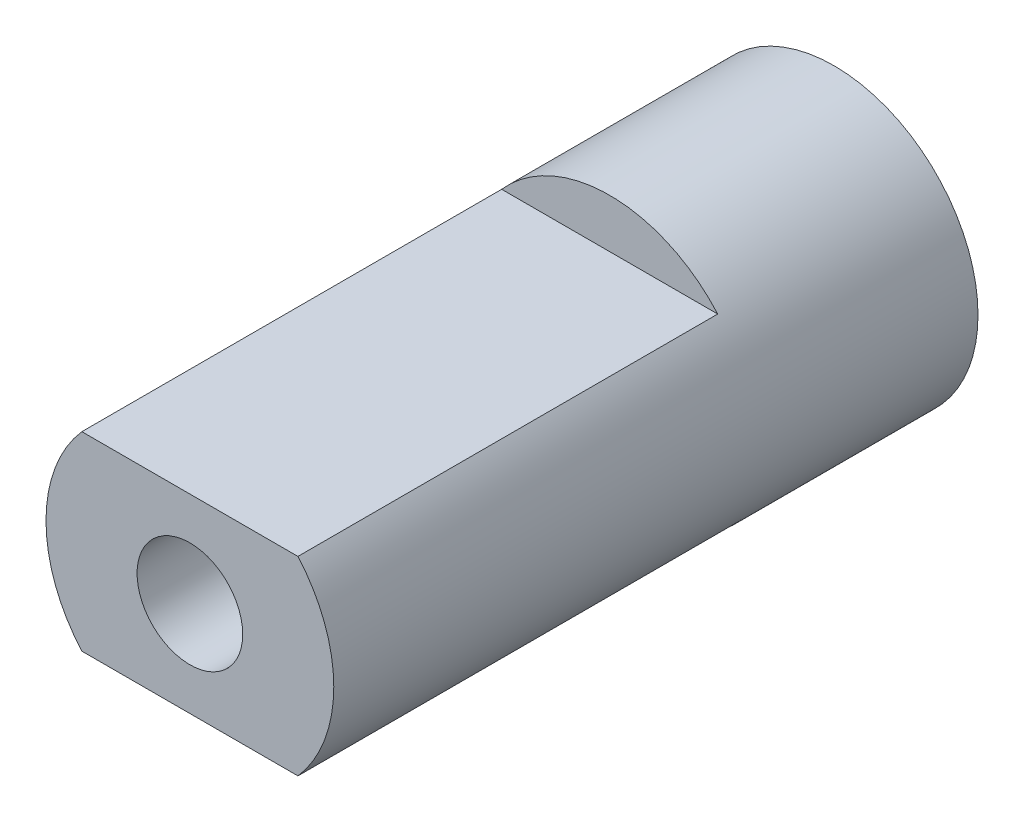
from build123d import *
from build123d.topology import SkipClean

# Parameters (mm, degrees)
SKETCH1_R           = 1
BOSS_EXTRUDE1_DEPTH = 3
BOSS_EXTRUDE2_START = 0.5
SKETCH2_R           = 1.75
SKETCH2_R_2         = 1
BOSS_EXTRUDE2_DEPTH = 0.5
SKETCH3_R           = 2.725
SKETCH3_R_2         = 1
BOSS_EXTRUDE3_DEPTH = 10.3
CUT_EXTRUDE1_START  = -7.95
CUT_EXTRUDE1_DEPTH  = 7.95
CUT_EXTRUDE3_DEPTH  = 3.5
CUT_EXTRUDE4_START  = -8.4
CUT_EXTRUDE4_DEPTH  = 8.4
BOSS_EXTRUDE4_START = -12.2
SKETCH9_R           = 1
BOSS_EXTRUDE4_DEPTH = 12.2
BOSS_EXTRUDE5_START = 1.9
BOSS_EXTRUDE5_DEPTH = 1.9


with BuildPart() as part:
    # Sketch1 → Boss-Extrude1 (new body)
    with BuildSketch(Plane.XY):
        with BuildLine():
            Line((1.642723432, 9.052152215), (1.930369102, 8.457499638))
            Line((1.930369102, 8.457499638), (1.813545612, 7.945662484))
            ThreePointArc((1.813545612, 7.945662484), (1.99137431, 7.902969591), (2.168200291, 7.856297315))
            ThreePointArc((2.168200291, 7.856297315), (2.343934519, 7.805669156), (2.518488504, 7.751110608))
            Line((2.518488504, 7.751110608), (2.680722426, 8.250415279))
            Line((2.680722426, 8.250415279), (3.232648382, 8.61336081))
            Line((3.232648382, 8.61336081), (3.409492149, 7.976903427))
            Line((3.409492149, 7.976903427), (3.203154008, 7.494151346))
            ThreePointArc((3.203154008, 7.494151346), (3.370501815, 7.420392005), (3.536152474, 7.342896273))
            ThreePointArc((3.536152474, 7.342896273), (3.700022573, 7.261703172), (3.862029599, 7.176853585))
            Line((3.862029599, 7.176853585), (4.110810647, 7.639166239))
            Line((4.110810647, 7.639166239), (4.718673352, 7.897728901))
            Line((4.718673352, 7.897728901), (4.779031314, 7.239922976))
            Line((4.779031314, 7.239922976), (4.489810399, 6.801772018))
            ThreePointArc((4.489810399, 6.801772018), (4.641298619, 6.699316915), (4.790449806, 6.593488504))
            ThreePointArc((4.790449806, 6.593488504), (4.937188857, 6.484340073), (5.081441885, 6.371926582))
            Line((5.081441885, 6.371926582), (5.408774031, 6.78238811))
            Line((5.408774031, 6.78238811), (6.053036279, 6.928257487))
            Line((6.053036279, 6.928257487), (5.99496848, 6.270245444))
            Line((5.99496848, 6.270245444), (5.632160589, 5.89077814))
            ThreePointArc((5.632160589, 5.89077814), (5.762920267, 5.762920267), (5.89077814, 5.632160589))
            ThreePointArc((5.89077814, 5.632160589), (6.01566983, 5.498564949), (6.137532448, 5.362200616))
            Line((6.137532448, 5.362200616), (6.532894968, 5.707618447))
            Line((6.532894968, 5.707618447), (7.192849639, 5.736106177))
            Line((7.192849639, 5.736106177), (7.018222426, 5.099037064))
            Line((7.018222426, 5.099037064), (6.593488504, 4.790449806))
            ThreePointArc((6.593488504, 4.790449806), (6.699316915, 4.641298619), (6.801772018, 4.489810399))
            ThreePointArc((6.801772018, 4.489810399), (6.900802224, 4.336061424), (6.996357668, 4.180129111))
            Line((6.996357668, 4.180129111), (7.447043285, 4.449401231))
            Line((7.447043285, 4.449401231), (8.101478893, 4.359591695))
            Line((8.101478893, 4.359591695), (7.815904929, 3.763941437))
            Line((7.815904929, 3.763941437), (7.342896273, 3.536152474))
            ThreePointArc((7.342896273, 3.536152474), (7.420392005, 3.370501816), (7.494151346, 3.203154008))
            ThreePointArc((7.494151346, 3.203154008), (7.564137156, 3.034193316), (7.630314196, 2.863704816))
            Line((7.630314196, 2.863704816), (8.121837503, 3.048176599))
            Line((8.121837503, 3.048176599), (8.74971995, 2.842956348))
            Line((8.74971995, 2.842956348), (8.362377816, 2.307869635))
            Line((8.362377816, 2.307869635), (7.856297315, 2.168200292))
            ThreePointArc((7.856297315, 2.168200292), (7.902969591, 1.99137431), (7.945662484, 1.813545612))
            ThreePointArc((7.945662484, 1.813545612), (7.984354497, 1.634803739), (8.019026147, 1.455238692))
            Line((8.019026147, 1.455238692), (8.535589181, 1.548981062))
            Line((8.535589181, 1.548981062), (9.116737808, 1.234946046))
            Line((9.116737808, 1.234946046), (8.640077, 0.777621005))
            Line((8.640077, 0.777621005), (8.117190496, 0.730560368))
            ThreePointArc((8.117190496, 0.730560368), (8.131539232, 0.548242396), (8.141793492, 0.365648367))
            ThreePointArc((8.141793492, 0.365648367), (8.147948115, 0.182870224), (8.15, 0))
            Line((8.15, 0), (8.675, 0))
            Line((8.675, 0), (9.190736212, -0.412756439))
            Line((9.190736212, -0.412756439), (8.640077, -0.777621005))
            Line((8.640077, -0.777621005), (8.117190496, -0.730560367))
            ThreePointArc((8.117190496, -0.730560367), (8.098754511, -0.91251048), (8.076240558, -1.094001116))
            ThreePointArc((8.076240558, -1.094001116), (8.049659976, -1.27494089), (8.019026147, -1.455238693))
            Line((8.019026147, -1.455238693), (8.535589181, -1.548981063))
            Line((8.535589181, -1.548981063), (8.969336792, -2.047192592))
            Line((8.969336792, -2.047192592), (8.362377817, -2.307869635))
            Line((8.362377817, -2.307869635), (7.856297315, -2.168200291))
            ThreePointArc((7.856297315, -2.168200291), (7.805669156, -2.343934518), (7.751110608, -2.518488504))
            ThreePointArc((7.751110608, -2.518488504), (7.692649142, -2.691774355), (7.630314196, -2.863704816))
            Line((7.630314196, -2.863704816), (8.121837503, -3.048176599))
            Line((8.121837503, -3.048176599), (8.459655507, -3.615830291))
            Line((8.459655507, -3.615830291), (7.815904929, -3.763941437))
            Line((7.815904929, -3.763941437), (7.342896273, -3.536152474))
            ThreePointArc((7.342896273, -3.536152474), (7.261703172, -3.700022573), (7.176853585, -3.862029599))
            ThreePointArc((7.176853585, -3.862029599), (7.088390235, -4.022091977), (6.996357668, -4.180129111))
            Line((6.996357668, -4.180129111), (7.447043284, -4.449401232))
            Line((7.447043284, -4.449401232), (7.678073934, -5.068252229))
            Line((7.678073934, -5.068252229), (7.018222426, -5.099037063))
            Line((7.018222426, -5.099037063), (6.593488504, -4.790449806))
            ThreePointArc((6.593488504, -4.790449806), (6.484340073, -4.937188857), (6.371926582, -5.081441885))
            ThreePointArc((6.371926582, -5.081441885), (6.256304634, -5.223136254), (6.137532448, -5.362200617))
            Line((6.137532448, -5.362200617), (6.532894967, -5.707618448))
            Line((6.532894967, -5.707618448), (6.649712747, -6.357776371))
            Line((6.649712747, -6.357776371), (5.99496848, -6.270245444))
            Line((5.99496848, -6.270245444), (5.632160589, -5.89077814))
            ThreePointArc((5.632160589, -5.89077814), (5.498564949, -6.015669829), (5.362200616, -6.137532448))
            ThreePointArc((5.362200616, -6.137532448), (5.223136254, -6.256304634), (5.081441885, -6.371926582))
            Line((5.081441885, -6.371926582), (5.408774031, -6.782388111))
            Line((5.408774031, -6.782388111), (5.407624321, -7.442956348))
            Line((5.407624321, -7.442956348), (4.779031314, -7.239922976))
            Line((4.779031314, -7.239922976), (4.489810399, -6.801772018))
            ThreePointArc((4.489810399, -6.801772018), (4.336061424, -6.900802224), (4.180129111, -6.996357668))
            ThreePointArc((4.180129111, -6.996357668), (4.022091977, -7.088390235), (3.862029599, -7.176853585))
            Line((3.862029599, -7.176853585), (4.110810647, -7.639166239))
            Line((4.110810647, -7.639166239), (3.9917304, -8.288913585))
            Line((3.9917304, -8.288913585), (3.40949215, -7.976903427))
            Line((3.40949215, -7.976903427), (3.203154008, -7.494151346))
            ThreePointArc((3.203154008, -7.494151346), (3.034193316, -7.564137156), (2.863704816, -7.630314196))
            ThreePointArc((2.863704816, -7.630314196), (2.691774355, -7.692649142), (2.518488504, -7.751110608))
            Line((2.518488504, -7.751110608), (2.680722426, -8.250415279))
            Line((2.680722426, -8.250415279), (2.447538979, -8.868458318))
            Line((2.447538979, -8.868458318), (1.930369102, -8.457499638))
            Line((1.930369102, -8.457499638), (1.813545612, -7.945662484))
            ThreePointArc((1.813545612, -7.945662484), (1.634803739, -7.984354497), (1.455238693, -8.019026147))
            ThreePointArc((1.455238693, -8.019026147), (1.27494089, -8.049659976), (1.094001116, -8.076240558))
            Line((1.094001116, -8.076240558), (1.164473581, -8.596489183))
            Line((1.164473581, -8.596489183), (0.824681642, -9.162963505))
            Line((0.824681642, -9.162963505), (0.389202404, -8.666264852))
            Line((0.389202404, -8.666264852), (0.365648368, -8.141793492))
            ThreePointArc((0.365648368, -8.141793492), (0.182870224, -8.147948115), (0, -8.15))
            ThreePointArc((0, -8.15), (-0.182870224, -8.147948115), (-0.365648368, -8.141793492))
            Line((-0.365648368, -8.141793492), (-0.389202404, -8.666264852))
            Line((-0.389202404, -8.666264852), (-0.824681642, -9.162963505))
            Line((-0.824681642, -9.162963505), (-1.164473581, -8.596489183))
            Line((-1.164473581, -8.596489183), (-1.094001116, -8.076240558))
            ThreePointArc((-1.094001116, -8.076240558), (-1.27494089, -8.049659976), (-1.455238693, -8.019026147))
            ThreePointArc((-1.455238693, -8.019026147), (-1.634803739, -7.984354497), (-1.813545612, -7.945662484))
            Line((-1.813545612, -7.945662484), (-1.930369102, -8.457499638))
            Line((-1.930369102, -8.457499638), (-2.447538979, -8.868458318))
            Line((-2.447538979, -8.868458318), (-2.680722426, -8.250415279))
            Line((-2.680722426, -8.250415279), (-2.518488504, -7.751110608))
            ThreePointArc((-2.518488504, -7.751110608), (-2.691774355, -7.692649142), (-2.863704816, -7.630314196))
            ThreePointArc((-2.863704816, -7.630314196), (-3.034193316, -7.564137156), (-3.203154008, -7.494151346))
            Line((-3.203154008, -7.494151346), (-3.40949215, -7.976903427))
            Line((-3.40949215, -7.976903427), (-3.9917304, -8.288913585))
            Line((-3.9917304, -8.288913585), (-4.110810647, -7.639166239))
            Line((-4.110810647, -7.639166239), (-3.862029599, -7.176853585))
            ThreePointArc((-3.862029599, -7.176853585), (-4.022091977, -7.088390235), (-4.180129111, -6.996357668))
            ThreePointArc((-4.180129111, -6.996357668), (-4.336061424, -6.900802224), (-4.489810399, -6.801772018))
            Line((-4.489810399, -6.801772018), (-4.779031314, -7.239922976))
            Line((-4.779031314, -7.239922976), (-5.407624321, -7.442956348))
            Line((-5.407624321, -7.442956348), (-5.408774031, -6.782388111))
            Line((-5.408774031, -6.782388111), (-5.081441885, -6.371926582))
            ThreePointArc((-5.081441885, -6.371926582), (-5.223136254, -6.256304634), (-5.362200616, -6.137532448))
            ThreePointArc((-5.362200616, -6.137532448), (-5.498564949, -6.015669829), (-5.632160589, -5.89077814))
            Line((-5.632160589, -5.89077814), (-5.99496848, -6.270245444))
            Line((-5.99496848, -6.270245444), (-6.649712747, -6.357776371))
            Line((-6.649712747, -6.357776371), (-6.532894967, -5.707618448))
            Line((-6.532894967, -5.707618448), (-6.137532448, -5.362200617))
            ThreePointArc((-6.137532448, -5.362200617), (-6.256304634, -5.223136254), (-6.371926582, -5.081441885))
            ThreePointArc((-6.371926582, -5.081441885), (-6.484340073, -4.937188857), (-6.593488504, -4.790449806))
            Line((-6.593488504, -4.790449806), (-7.018222426, -5.099037063))
            Line((-7.018222426, -5.099037063), (-7.678073934, -5.068252229))
            Line((-7.678073934, -5.068252229), (-7.447043284, -4.449401232))
            Line((-7.447043284, -4.449401232), (-6.996357668, -4.180129111))
            ThreePointArc((-6.996357668, -4.180129111), (-7.088390235, -4.022091977), (-7.176853585, -3.862029599))
            ThreePointArc((-7.176853585, -3.862029599), (-7.261703172, -3.700022573), (-7.342896273, -3.536152474))
            Line((-7.342896273, -3.536152474), (-7.815904929, -3.763941437))
            Line((-7.815904929, -3.763941437), (-8.459655507, -3.615830291))
            Line((-8.459655507, -3.615830291), (-8.121837503, -3.048176599))
            Line((-8.121837503, -3.048176599), (-7.630314196, -2.863704816))
            ThreePointArc((-7.630314196, -2.863704816), (-7.692649142, -2.691774355), (-7.751110608, -2.518488504))
            ThreePointArc((-7.751110608, -2.518488504), (-7.805669156, -2.343934518), (-7.856297315, -2.168200291))
            Line((-7.856297315, -2.168200291), (-8.362377817, -2.307869635))
            Line((-8.362377817, -2.307869635), (-8.969336792, -2.047192592))
            Line((-8.969336792, -2.047192592), (-8.535589181, -1.548981063))
            Line((-8.535589181, -1.548981063), (-8.019026147, -1.455238693))
            ThreePointArc((-8.019026147, -1.455238693), (-8.049659976, -1.27494089), (-8.076240558, -1.094001116))
            ThreePointArc((-8.076240558, -1.094001116), (-8.098754511, -0.91251048), (-8.117190496, -0.730560367))
            Line((-8.117190496, -0.730560367), (-8.640077, -0.777621005))
            Line((-8.640077, -0.777621005), (-9.190736212, -0.412756439))
            Line((-9.190736212, -0.412756439), (-8.675, 0))
            Line((-8.675, 0), (-8.15, 0))
            ThreePointArc((-8.15, 0), (-8.147948115, 0.182870224), (-8.141793492, 0.365648367))
            ThreePointArc((-8.141793492, 0.365648367), (-8.131539232, 0.548242396), (-8.117190496, 0.730560368))
            Line((-8.117190496, 0.730560368), (-8.640077, 0.777621005))
            Line((-8.640077, 0.777621005), (-9.116737808, 1.234946046))
            Line((-9.116737808, 1.234946046), (-8.535589181, 1.548981062))
            Line((-8.535589181, 1.548981062), (-8.019026147, 1.455238692))
            ThreePointArc((-8.019026147, 1.455238692), (-7.984354497, 1.634803739), (-7.945662484, 1.813545612))
            ThreePointArc((-7.945662484, 1.813545612), (-7.902969591, 1.99137431), (-7.856297315, 2.168200292))
            Line((-7.856297315, 2.168200292), (-8.362377816, 2.307869635))
            Line((-8.362377816, 2.307869635), (-8.74971995, 2.842956348))
            Line((-8.74971995, 2.842956348), (-8.121837503, 3.048176599))
            Line((-8.121837503, 3.048176599), (-7.630314196, 2.863704816))
            ThreePointArc((-7.630314196, 2.863704816), (-7.564137156, 3.034193316), (-7.494151346, 3.203154008))
            ThreePointArc((-7.494151346, 3.203154008), (-7.420392005, 3.370501816), (-7.342896273, 3.536152474))
            Line((-7.342896273, 3.536152474), (-7.815904929, 3.763941437))
            Line((-7.815904929, 3.763941437), (-8.101478893, 4.359591695))
            Line((-8.101478893, 4.359591695), (-7.447043285, 4.449401231))
            Line((-7.447043285, 4.449401231), (-6.996357668, 4.180129111))
            ThreePointArc((-6.996357668, 4.180129111), (-6.900802224, 4.336061424), (-6.801772018, 4.489810399))
            ThreePointArc((-6.801772018, 4.489810399), (-6.699316915, 4.641298619), (-6.593488504, 4.790449806))
            Line((-6.593488504, 4.790449806), (-7.018222426, 5.099037064))
            Line((-7.018222426, 5.099037064), (-7.192849639, 5.736106177))
            Line((-7.192849639, 5.736106177), (-6.532894968, 5.707618447))
            Line((-6.532894968, 5.707618447), (-6.137532448, 5.362200616))
            ThreePointArc((-6.137532448, 5.362200616), (-6.01566983, 5.498564949), (-5.89077814, 5.632160589))
            ThreePointArc((-5.89077814, 5.632160589), (-5.762920267, 5.762920267), (-5.632160589, 5.89077814))
            Line((-5.632160589, 5.89077814), (-5.99496848, 6.270245444))
            Line((-5.99496848, 6.270245444), (-6.053036279, 6.928257487))
            Line((-6.053036279, 6.928257487), (-5.408774031, 6.78238811))
            Line((-5.408774031, 6.78238811), (-5.081441885, 6.371926582))
            ThreePointArc((-5.081441885, 6.371926582), (-4.937188857, 6.484340073), (-4.790449806, 6.593488504))
            ThreePointArc((-4.790449806, 6.593488504), (-4.641298619, 6.699316915), (-4.489810399, 6.801772018))
            Line((-4.489810399, 6.801772018), (-4.779031314, 7.239922976))
            Line((-4.779031314, 7.239922976), (-4.718673352, 7.897728901))
            Line((-4.718673352, 7.897728901), (-4.110810647, 7.639166239))
            Line((-4.110810647, 7.639166239), (-3.862029599, 7.176853585))
            ThreePointArc((-3.862029599, 7.176853585), (-3.700022573, 7.261703172), (-3.536152474, 7.342896273))
            ThreePointArc((-3.536152474, 7.342896273), (-3.370501815, 7.420392005), (-3.203154008, 7.494151346))
            Line((-3.203154008, 7.494151346), (-3.409492149, 7.976903427))
            Line((-3.409492149, 7.976903427), (-3.232648382, 8.61336081))
            Line((-3.232648382, 8.61336081), (-2.680722426, 8.250415279))
            Line((-2.680722426, 8.250415279), (-2.518488504, 7.751110608))
            ThreePointArc((-2.518488504, 7.751110608), (-2.343934519, 7.805669156), (-2.168200291, 7.856297315))
            ThreePointArc((-2.168200291, 7.856297315), (-1.99137431, 7.902969591), (-1.813545612, 7.945662484))
            Line((-1.813545612, 7.945662484), (-1.930369102, 8.457499638))
            Line((-1.930369102, 8.457499638), (-1.642723432, 9.052152215))
            Line((-1.642723432, 9.052152215), (-1.164473581, 8.596489183))
            Line((-1.164473581, 8.596489183), (-1.094001117, 8.076240558))
            ThreePointArc((-1.094001117, 8.076240558), (-0.91251048, 8.098754511), (-0.730560368, 8.117190496))
            ThreePointArc((-0.730560368, 8.117190496), (-0.548242396, 8.131539232), (-0.365648367, 8.141793492))
            Line((-0.365648367, 8.141793492), (-0.389202403, 8.666264852))
            Line((-0.389202403, 8.666264852), (0, 9.2))
            Line((0, 9.2), (0.389202403, 8.666264852))
            Line((0.389202403, 8.666264852), (0.365648367, 8.141793492))
            ThreePointArc((0.365648367, 8.141793492), (0.548242396, 8.131539232), (0.730560368, 8.117190496))
            ThreePointArc((0.730560368, 8.117190496), (0.91251048, 8.098754511), (1.094001117, 8.076240558))
            Line((1.094001117, 8.076240558), (1.164473581, 8.596489183))
            Line((1.164473581, 8.596489183), (1.642723432, 9.052152215))
        make_face()
        Circle(SKETCH1_R, mode=Mode.SUBTRACT)
    extrude(amount=BOSS_EXTRUDE1_DEPTH)

    # Sketch2 → Boss-Extrude2 (add)
    with SkipClean():  # the faces are left unmerged after this step: merging them gives an invalid solid
        with BuildSketch(Plane(origin=(0, 0, 0), x_dir=(-1, 0, 0), z_dir=(0, 0, -1)).offset(BOSS_EXTRUDE2_START)):
            with Locations(Location((0, 0, 0), (0, 0, 180))):
                Circle(SKETCH2_R)
            Circle(SKETCH2_R_2, mode=Mode.SUBTRACT)
        extrude(amount=-BOSS_EXTRUDE2_DEPTH)

    # Sketch3 → Boss-Extrude3 (add)
    with BuildSketch(Plane.XY.offset(3)):
        with Locations(Location((0, 0, 0), (0, 0, 180))):
            Circle(SKETCH3_R)
        with Locations(Location((0, 0, 0), (0, 0, 180))):
            Circle(SKETCH3_R_2, mode=Mode.SUBTRACT)
    extrude(amount=BOSS_EXTRUDE3_DEPTH)

    # Sketch4 → Cut-Extrude1 (cut)
    with BuildSketch(Plane.XY.offset(13.3).offset(CUT_EXTRUDE1_START)):
        with BuildLine():
            Line((-2.045880006, -1.8), (2.045880006, -1.8))
            ThreePointArc((2.045880006, -1.8), (0, -2.725), (-2.045880006, -1.8))
        make_face()
        with BuildLine():
            Line((-2.045880006, 1.8), (2.045880006, 1.8))
            ThreePointArc((2.045880006, 1.8), (0, 2.725), (-2.045880006, 1.8))
        make_face()
    extrude(amount=CUT_EXTRUDE1_DEPTH, mode=Mode.SUBTRACT)

    # Sketch6 → Cut-Extrude3 (cut)
    with BuildSketch(Plane(origin=(0, 0, -0.5), x_dir=(-1, 0, 0), z_dir=(0, 0, -1))):
        with BuildLine():
            Line((0.365648367, 8.141793492), (0.389202403, 8.666264852))
            Line((0.389202403, 8.666264852), (0, 9.2))
            Line((0, 9.2), (-0.389202403, 8.666264852))
            Line((-0.389202403, 8.666264852), (-0.365648367, 8.141793492))
            ThreePointArc((-0.365648367, 8.141793492), (-0.730560368, 8.117190496), (-1.094001117, 8.076240558))
            Line((-1.094001117, 8.076240558), (-1.164473581, 8.596489183))
            Line((-1.164473581, 8.596489183), (-1.642723432, 9.052152215))
            Line((-1.642723432, 9.052152215), (-1.930369102, 8.457499638))
            Line((-1.930369102, 8.457499638), (-1.813545612, 7.945662484))
            ThreePointArc((-1.813545612, 7.945662484), (-2.168200291, 7.856297315), (-2.518488504, 7.751110608))
            Line((-2.518488504, 7.751110608), (-2.680722426, 8.250415279))
            Line((-2.680722426, 8.250415279), (-3.232648382, 8.61336081))
            Line((-3.232648382, 8.61336081), (-3.409492149, 7.976903427))
            Line((-3.409492149, 7.976903427), (-3.203154008, 7.494151346))
            ThreePointArc((-3.203154008, 7.494151346), (-3.536152474, 7.342896273), (-3.862029599, 7.176853585))
            Line((-3.862029599, 7.176853585), (-4.110810647, 7.639166239))
            Line((-4.110810647, 7.639166239), (-4.718673352, 7.897728901))
            Line((-4.718673352, 7.897728901), (-4.779031314, 7.239922976))
            Line((-4.779031314, 7.239922976), (-4.489810399, 6.801772018))
            ThreePointArc((-4.489810399, 6.801772018), (-4.790449806, 6.593488504), (-5.081441885, 6.371926582))
            Line((-5.081441885, 6.371926582), (-5.408774031, 6.78238811))
            Line((-5.408774031, 6.78238811), (-6.053036279, 6.928257487))
            Line((-6.053036279, 6.928257487), (-5.99496848, 6.270245444))
            Line((-5.99496848, 6.270245444), (-5.632160589, 5.89077814))
            ThreePointArc((-5.632160589, 5.89077814), (-5.89077814, 5.632160589), (-6.137532448, 5.362200616))
            Line((-6.137532448, 5.362200616), (-6.532894968, 5.707618447))
            Line((-6.532894968, 5.707618447), (-7.192849639, 5.736106177))
            Line((-7.192849639, 5.736106177), (-7.018222426, 5.099037064))
            Line((-7.018222426, 5.099037064), (-6.593488504, 4.790449806))
            ThreePointArc((-6.593488504, 4.790449806), (-6.801772018, 4.489810399), (-6.996357668, 4.180129111))
            Line((-6.996357668, 4.180129111), (-7.447043285, 4.449401231))
            Line((-7.447043285, 4.449401231), (-8.101478893, 4.359591695))
            Line((-8.101478893, 4.359591695), (-7.815904929, 3.763941437))
            Line((-7.815904929, 3.763941437), (-7.342896273, 3.536152474))
            ThreePointArc((-7.342896273, 3.536152474), (-7.494151346, 3.203154008), (-7.630314196, 2.863704816))
            Line((-7.630314196, 2.863704816), (-8.121837503, 3.048176599))
            Line((-8.121837503, 3.048176599), (-8.74971995, 2.842956348))
            Line((-8.74971995, 2.842956348), (-8.362377816, 2.307869635))
            Line((-8.362377816, 2.307869635), (-7.856297315, 2.168200292))
            ThreePointArc((-7.856297315, 2.168200292), (-7.945662484, 1.813545612), (-8.019026147, 1.455238692))
            Line((-8.019026147, 1.455238692), (-8.535589181, 1.548981062))
            Line((-8.535589181, 1.548981062), (-9.116737808, 1.234946046))
            Line((-9.116737808, 1.234946046), (-8.640077, 0.777621005))
            Line((-8.640077, 0.777621005), (-8.117190496, 0.730560368))
            ThreePointArc((-8.117190496, 0.730560368), (-8.141793492, 0.365648367), (-8.15, 0))
            Line((-8.15, 0), (-8.675, 0))
            Line((-8.675, 0), (-9.190736212, -0.412756439))
            Line((-9.190736212, -0.412756439), (-8.640077, -0.777621005))
            Line((-8.640077, -0.777621005), (-8.117190496, -0.730560367))
            ThreePointArc((-8.117190496, -0.730560367), (-8.076240558, -1.094001116), (-8.019026147, -1.455238693))
            Line((-8.019026147, -1.455238693), (-8.535589181, -1.548981063))
            Line((-8.535589181, -1.548981063), (-8.969336792, -2.047192592))
            Line((-8.969336792, -2.047192592), (-8.362377817, -2.307869635))
            Line((-8.362377817, -2.307869635), (-7.856297315, -2.168200291))
            ThreePointArc((-7.856297315, -2.168200291), (-7.751110608, -2.518488504), (-7.630314196, -2.863704816))
            Line((-7.630314196, -2.863704816), (-8.121837503, -3.048176599))
            Line((-8.121837503, -3.048176599), (-8.459655507, -3.615830291))
            Line((-8.459655507, -3.615830291), (-7.815904929, -3.763941437))
            Line((-7.815904929, -3.763941437), (-7.342896273, -3.536152474))
            ThreePointArc((-7.342896273, -3.536152474), (-7.176853585, -3.862029599), (-6.996357668, -4.180129111))
            Line((-6.996357668, -4.180129111), (-7.447043284, -4.449401232))
            Line((-7.447043284, -4.449401232), (-7.678073934, -5.068252229))
            Line((-7.678073934, -5.068252229), (-7.018222426, -5.099037063))
            Line((-7.018222426, -5.099037063), (-6.593488504, -4.790449806))
            ThreePointArc((-6.593488504, -4.790449806), (-6.371926582, -5.081441885), (-6.137532448, -5.362200617))
            Line((-6.137532448, -5.362200617), (-6.532894967, -5.707618448))
            Line((-6.532894967, -5.707618448), (-6.649712747, -6.357776371))
            Line((-6.649712747, -6.357776371), (-5.99496848, -6.270245444))
            Line((-5.99496848, -6.270245444), (-5.632160589, -5.89077814))
            ThreePointArc((-5.632160589, -5.89077814), (-5.362200616, -6.137532448), (-5.081441885, -6.371926582))
            Line((-5.081441885, -6.371926582), (-5.408774031, -6.782388111))
            Line((-5.408774031, -6.782388111), (-5.407624321, -7.442956348))
            Line((-5.407624321, -7.442956348), (-4.779031314, -7.239922976))
            Line((-4.779031314, -7.239922976), (-4.489810399, -6.801772018))
            ThreePointArc((-4.489810399, -6.801772018), (-4.180129111, -6.996357668), (-3.862029599, -7.176853585))
            Line((-3.862029599, -7.176853585), (-4.110810647, -7.639166239))
            Line((-4.110810647, -7.639166239), (-3.9917304, -8.288913585))
            Line((-3.9917304, -8.288913585), (-3.40949215, -7.976903427))
            Line((-3.40949215, -7.976903427), (-3.203154008, -7.494151346))
            ThreePointArc((-3.203154008, -7.494151346), (-2.863704816, -7.630314196), (-2.518488504, -7.751110608))
            Line((-2.518488504, -7.751110608), (-2.680722426, -8.250415279))
            Line((-2.680722426, -8.250415279), (-2.447538979, -8.868458318))
            Line((-2.447538979, -8.868458318), (-1.930369102, -8.457499638))
            Line((-1.930369102, -8.457499638), (-1.813545612, -7.945662484))
            ThreePointArc((-1.813545612, -7.945662484), (-1.455238693, -8.019026147), (-1.094001116, -8.076240558))
            Line((-1.094001116, -8.076240558), (-1.164473581, -8.596489183))
            Line((-1.164473581, -8.596489183), (-0.824681642, -9.162963505))
            Line((-0.824681642, -9.162963505), (-0.389202404, -8.666264852))
            Line((-0.389202404, -8.666264852), (-0.365648368, -8.141793492))
            ThreePointArc((-0.365648368, -8.141793492), (0, -8.15), (0.365648368, -8.141793492))
            Line((0.365648368, -8.141793492), (0.389202404, -8.666264852))
            Line((0.389202404, -8.666264852), (0.824681642, -9.162963505))
            Line((0.824681642, -9.162963505), (1.164473581, -8.596489183))
            Line((1.164473581, -8.596489183), (1.094001116, -8.076240558))
            ThreePointArc((1.094001116, -8.076240558), (1.455238693, -8.019026147), (1.813545612, -7.945662484))
            Line((1.813545612, -7.945662484), (1.930369102, -8.457499638))
            Line((1.930369102, -8.457499638), (2.447538979, -8.868458318))
            Line((2.447538979, -8.868458318), (2.680722426, -8.250415279))
            Line((2.680722426, -8.250415279), (2.518488504, -7.751110608))
            ThreePointArc((2.518488504, -7.751110608), (2.863704816, -7.630314196), (3.203154008, -7.494151346))
            Line((3.203154008, -7.494151346), (3.40949215, -7.976903427))
            Line((3.40949215, -7.976903427), (3.9917304, -8.288913585))
            Line((3.9917304, -8.288913585), (4.110810647, -7.639166239))
            Line((4.110810647, -7.639166239), (3.862029599, -7.176853585))
            ThreePointArc((3.862029599, -7.176853585), (4.180129111, -6.996357668), (4.489810399, -6.801772018))
            Line((4.489810399, -6.801772018), (4.779031314, -7.239922976))
            Line((4.779031314, -7.239922976), (5.407624321, -7.442956348))
            Line((5.407624321, -7.442956348), (5.408774031, -6.782388111))
            Line((5.408774031, -6.782388111), (5.081441885, -6.371926582))
            ThreePointArc((5.081441885, -6.371926582), (5.362200616, -6.137532448), (5.632160589, -5.89077814))
            Line((5.632160589, -5.89077814), (5.99496848, -6.270245444))
            Line((5.99496848, -6.270245444), (6.649712747, -6.357776371))
            Line((6.649712747, -6.357776371), (6.532894967, -5.707618448))
            Line((6.532894967, -5.707618448), (6.137532448, -5.362200617))
            ThreePointArc((6.137532448, -5.362200617), (6.371926582, -5.081441885), (6.593488504, -4.790449806))
            Line((6.593488504, -4.790449806), (7.018222426, -5.099037063))
            Line((7.018222426, -5.099037063), (7.678073934, -5.068252229))
            Line((7.678073934, -5.068252229), (7.447043284, -4.449401232))
            Line((7.447043284, -4.449401232), (6.996357668, -4.180129111))
            ThreePointArc((6.996357668, -4.180129111), (7.176853585, -3.862029599), (7.342896273, -3.536152474))
            Line((7.342896273, -3.536152474), (7.815904929, -3.763941437))
            Line((7.815904929, -3.763941437), (8.459655507, -3.615830291))
            Line((8.459655507, -3.615830291), (8.121837503, -3.048176599))
            Line((8.121837503, -3.048176599), (7.630314196, -2.863704816))
            ThreePointArc((7.630314196, -2.863704816), (7.751110608, -2.518488504), (7.856297315, -2.168200291))
            Line((7.856297315, -2.168200291), (8.362377817, -2.307869635))
            Line((8.362377817, -2.307869635), (8.969336792, -2.047192592))
            Line((8.969336792, -2.047192592), (8.535589181, -1.548981063))
            Line((8.535589181, -1.548981063), (8.019026147, -1.455238693))
            ThreePointArc((8.019026147, -1.455238693), (8.076240558, -1.094001116), (8.117190496, -0.730560367))
            Line((8.117190496, -0.730560367), (8.640077, -0.777621005))
            Line((8.640077, -0.777621005), (9.190736212, -0.412756439))
            Line((9.190736212, -0.412756439), (8.675, 0))
            Line((8.675, 0), (8.15, 0))
            ThreePointArc((8.15, 0), (8.141793492, 0.365648367), (8.117190496, 0.730560368))
            Line((8.117190496, 0.730560368), (8.640077, 0.777621005))
            Line((8.640077, 0.777621005), (9.116737808, 1.234946046))
            Line((9.116737808, 1.234946046), (8.535589181, 1.548981062))
            Line((8.535589181, 1.548981062), (8.019026147, 1.455238692))
            ThreePointArc((8.019026147, 1.455238692), (7.945662484, 1.813545612), (7.856297315, 2.168200292))
            Line((7.856297315, 2.168200292), (8.362377816, 2.307869635))
            Line((8.362377816, 2.307869635), (8.74971995, 2.842956348))
            Line((8.74971995, 2.842956348), (8.121837503, 3.048176599))
            Line((8.121837503, 3.048176599), (7.630314196, 2.863704816))
            ThreePointArc((7.630314196, 2.863704816), (7.494151346, 3.203154008), (7.342896273, 3.536152474))
            Line((7.342896273, 3.536152474), (7.815904929, 3.763941437))
            Line((7.815904929, 3.763941437), (8.101478893, 4.359591695))
            Line((8.101478893, 4.359591695), (7.447043285, 4.449401231))
            Line((7.447043285, 4.449401231), (6.996357668, 4.180129111))
            ThreePointArc((6.996357668, 4.180129111), (6.801772018, 4.489810399), (6.593488504, 4.790449806))
            Line((6.593488504, 4.790449806), (7.018222426, 5.099037064))
            Line((7.018222426, 5.099037064), (7.192849639, 5.736106177))
            Line((7.192849639, 5.736106177), (6.532894968, 5.707618447))
            Line((6.532894968, 5.707618447), (6.137532448, 5.362200616))
            ThreePointArc((6.137532448, 5.362200616), (5.89077814, 5.632160589), (5.632160589, 5.89077814))
            Line((5.632160589, 5.89077814), (5.99496848, 6.270245444))
            Line((5.99496848, 6.270245444), (6.053036279, 6.928257487))
            Line((6.053036279, 6.928257487), (5.408774031, 6.78238811))
            Line((5.408774031, 6.78238811), (5.081441885, 6.371926582))
            ThreePointArc((5.081441885, 6.371926582), (4.790449806, 6.593488504), (4.489810399, 6.801772018))
            Line((4.489810399, 6.801772018), (4.779031314, 7.239922976))
            Line((4.779031314, 7.239922976), (4.718673352, 7.897728901))
            Line((4.718673352, 7.897728901), (4.110810647, 7.639166239))
            Line((4.110810647, 7.639166239), (3.862029599, 7.176853585))
            ThreePointArc((3.862029599, 7.176853585), (3.536152474, 7.342896273), (3.203154008, 7.494151346))
            Line((3.203154008, 7.494151346), (3.409492149, 7.976903427))
            Line((3.409492149, 7.976903427), (3.232648382, 8.61336081))
            Line((3.232648382, 8.61336081), (2.680722426, 8.250415279))
            Line((2.680722426, 8.250415279), (2.518488504, 7.751110608))
            ThreePointArc((2.518488504, 7.751110608), (2.168200291, 7.856297315), (1.813545612, 7.945662484))
            Line((1.813545612, 7.945662484), (1.930369102, 8.457499638))
            Line((1.930369102, 8.457499638), (1.642723432, 9.052152215))
            Line((1.642723432, 9.052152215), (1.164473581, 8.596489183))
            Line((1.164473581, 8.596489183), (1.094001117, 8.076240558))
            ThreePointArc((1.094001117, 8.076240558), (0.730560368, 8.117190496), (0.365648367, 8.141793492))
        make_face()
    extrude(amount=-CUT_EXTRUDE3_DEPTH, mode=Mode.SUBTRACT)

    # Sketch8 → Cut-Extrude4 (cut)
    with BuildSketch(Plane.XY.offset(13.3).offset(CUT_EXTRUDE4_START)):
        with BuildLine():
            Line((2.045880006, -1.8), (-2.045880006, -1.8))
            ThreePointArc((-2.045880006, -1.8), (0, -2.725), (2.045880006, -1.8))
        make_face()
    extrude(amount=CUT_EXTRUDE4_DEPTH, mode=Mode.SUBTRACT)

    # Sketch9 → Boss-Extrude4 (add)
    with BuildSketch(Plane.XY.offset(13.3).offset(BOSS_EXTRUDE4_START)):
        with BuildLine():
            Line((2.045880006, 1.8), (-2.045880006, 1.8))
            ThreePointArc((-2.045880006, 1.8), (-2.725, 0), (-2.045880006, -1.8))
            Line((-2.045880006, -1.8), (2.045880006, -1.8))
            ThreePointArc((2.045880006, -1.8), (2.725, 0), (2.045880006, 1.8))
        make_face()
        Circle(SKETCH9_R, mode=Mode.SUBTRACT)
    extrude(amount=BOSS_EXTRUDE4_DEPTH)

    # Sketch10 → Boss-Extrude5 (add)
    with SkipClean():  # the faces are left unmerged after this step: merging them gives an invalid solid
        with BuildSketch(Plane(origin=(0, 0, 3), x_dir=(-1, 0, 0), z_dir=(0, 0, -1)).offset(BOSS_EXTRUDE5_START)):
            with BuildLine():
                Line((2.045880006, -1.8), (-2.045880006, -1.8))
                ThreePointArc((-2.045880006, -1.8), (0, -2.725), (2.045880006, -1.8))
            make_face()
            with BuildLine():
                Line((-2.045880006, 1.8), (2.045880006, 1.8))
                ThreePointArc((2.045880006, 1.8), (0, 2.725), (-2.045880006, 1.8))
            make_face()
        extrude(amount=-BOSS_EXTRUDE5_DEPTH)


solid = part.part
